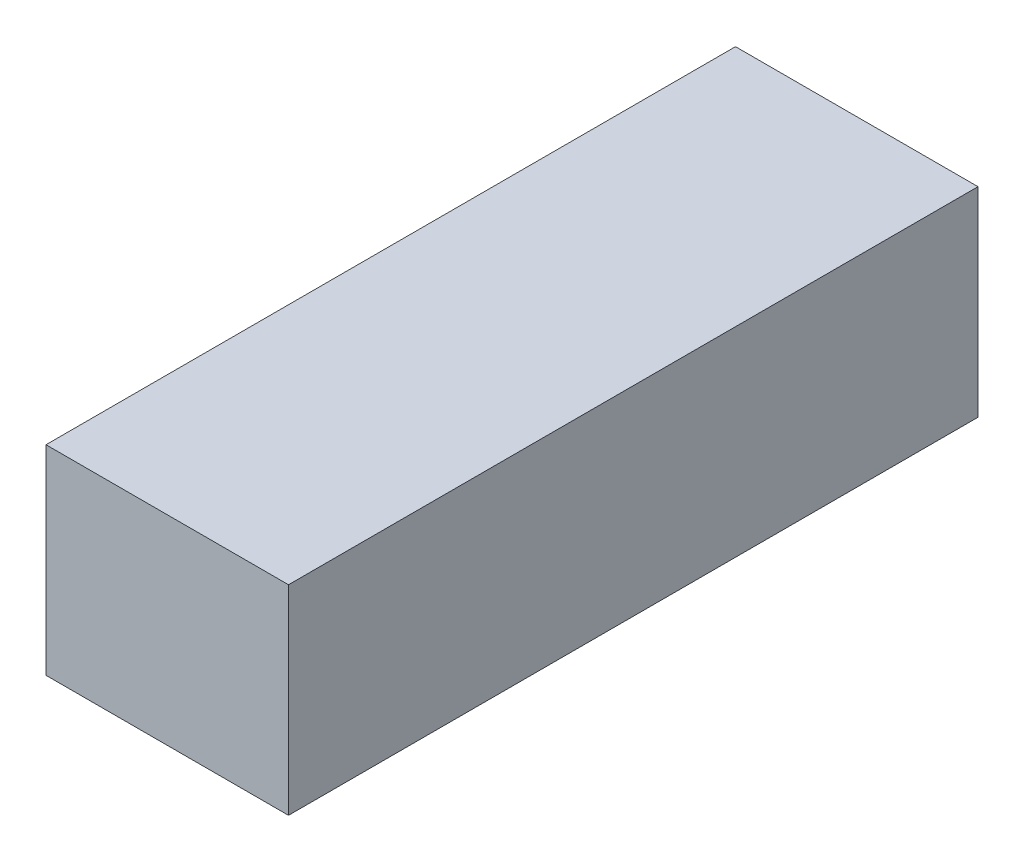
from build123d import *

# Parameters (mm, degrees)
SKETCH1_W           = 51
SKETCH1_H           = 42
BOSS_EXTRUDE1_DEPTH = 145


with BuildPart() as part:
    # Sketch1 → Boss-Extrude1 (new body)
    with BuildSketch(Plane.XY):
        Rectangle(SKETCH1_W, SKETCH1_H)
    extrude(amount=BOSS_EXTRUDE1_DEPTH)


solid = part.part
